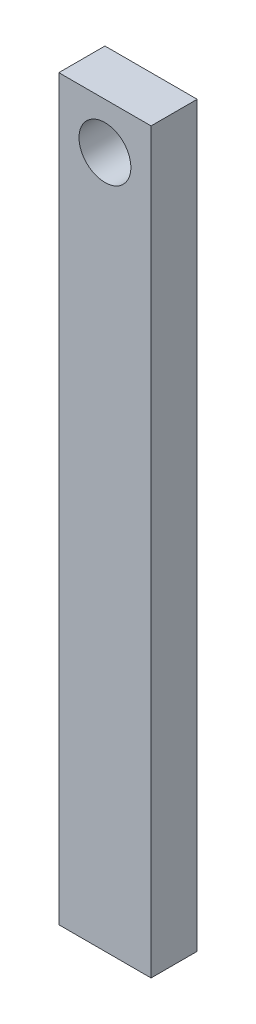
from build123d import *

# Parameters (mm, degrees)
SKETCH1_W           = 50.8
SKETCH1_H           = 406.4
SKETCH1_R           = 14.2875
BOSS_EXTRUDE1_DEPTH = 25.4


with BuildPart() as part:
    # Sketch1 → Boss-Extrude1 (new body)
    with BuildSketch(Plane.XY):
        with Locations((25.4, 203.2)):
            Rectangle(SKETCH1_W, SKETCH1_H)
        with Locations((25.4, 381)):
            Circle(SKETCH1_R, mode=Mode.SUBTRACT)
    extrude(amount=BOSS_EXTRUDE1_DEPTH)


solid = part.part
